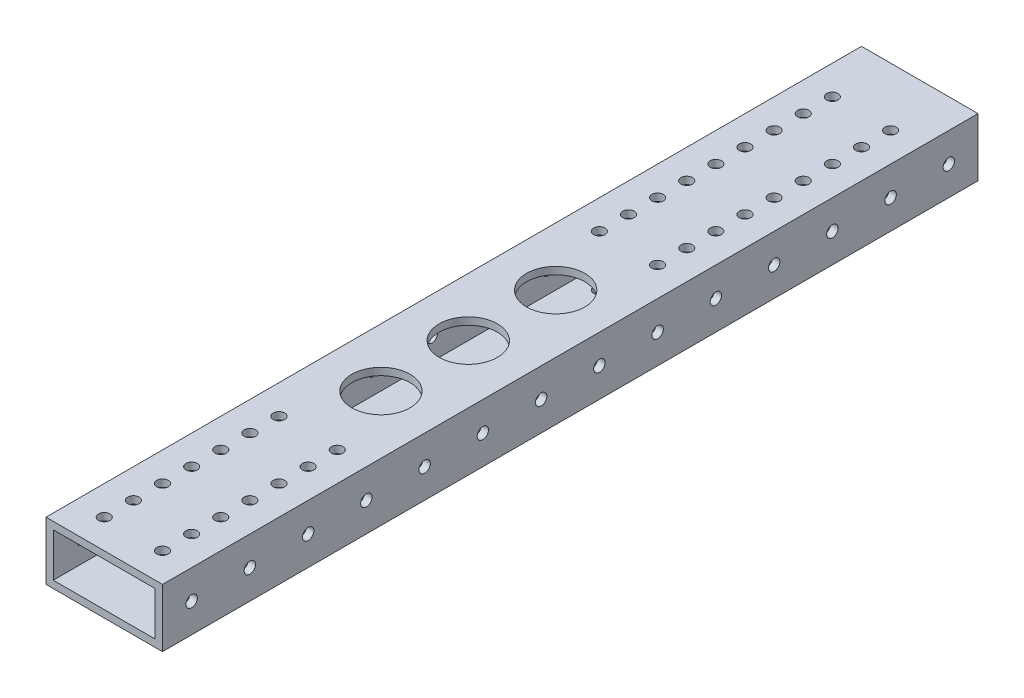
from build123d import *

# Parameters (mm, degrees)
SKETCH1_W           = 50.8
SKETCH1_H           = 25.4
SKETCH1_W_2         = 44.45
SKETCH1_H_2         = 19.05
BOSS_EXTRUDE1_DEPTH = 177.8
CUT_EXTRUDE1_REACH  = 27.4
SKETCH2_R           = 2.4892
SKETCH3_R           = 2.4892
CUT_EXTRUDE2_DEPTH  = 51.8
SKETCH4_R           = 2.4892
CUT_EXTRUDE3_DEPTH  = 26.4
SKETCH5_R           = 12.7
CUT_EXTRUDE4_DEPTH  = 26.4


with BuildPart() as part:
    # Sketch1 → Boss-Extrude1 (new body, symmetric)
    with BuildSketch(Plane.XY):
        Rectangle(SKETCH1_W, SKETCH1_H)
        Rectangle(SKETCH1_W_2, SKETCH1_H_2, mode=Mode.SUBTRACT)
    extrude(amount=BOSS_EXTRUDE1_DEPTH, both=True)

    # Sketch2 → Cut-Extrude1 (cut, up to next)
    with BuildSketch(Plane.XZ.offset(-12.7), mode=Mode.PRIVATE) as cut_extrude1_sk1:
        with Locations((-12.7, 165.1)):
            Circle(SKETCH2_R)
    cut_extrude1_tool1 = extrude(cut_extrude1_sk1.sketch, amount=CUT_EXTRUDE1_REACH, mode=Mode.PRIVATE) & part.part
    add(cut_extrude1_tool1.solids().sort_by_distance((-12.7, 12.7, 165.1))[0], mode=Mode.SUBTRACT)
    # Sketch2 → Cut-Extrude1 (cut, up to next)
    with BuildSketch(Plane.XZ.offset(-12.7), mode=Mode.PRIVATE) as cut_extrude1_sk2:
        with Locations((-12.7, 152.4)):
            Circle(SKETCH2_R)
    cut_extrude1_tool2 = extrude(cut_extrude1_sk2.sketch, amount=CUT_EXTRUDE1_REACH, mode=Mode.PRIVATE) & part.part
    add(cut_extrude1_tool2.solids().sort_by_distance((-12.7, 12.7, 152.4))[0], mode=Mode.SUBTRACT)
    # Sketch2 → Cut-Extrude1 (cut, up to next)
    with BuildSketch(Plane.XZ.offset(-12.7), mode=Mode.PRIVATE) as cut_extrude1_sk3:
        with Locations((-12.7, 139.7)):
            Circle(SKETCH2_R)
    cut_extrude1_tool3 = extrude(cut_extrude1_sk3.sketch, amount=CUT_EXTRUDE1_REACH, mode=Mode.PRIVATE) & part.part
    add(cut_extrude1_tool3.solids().sort_by_distance((-12.7, 12.7, 139.7))[0], mode=Mode.SUBTRACT)
    # Sketch2 → Cut-Extrude1 (cut, up to next)
    with BuildSketch(Plane.XZ.offset(-12.7), mode=Mode.PRIVATE) as cut_extrude1_sk4:
        with Locations((-12.7, 127)):
            Circle(SKETCH2_R)
    cut_extrude1_tool4 = extrude(cut_extrude1_sk4.sketch, amount=CUT_EXTRUDE1_REACH, mode=Mode.PRIVATE) & part.part
    add(cut_extrude1_tool4.solids().sort_by_distance((-12.7, 12.7, 127))[0], mode=Mode.SUBTRACT)
    # Sketch2 → Cut-Extrude1 (cut, up to next)
    with BuildSketch(Plane.XZ.offset(-12.7), mode=Mode.PRIVATE) as cut_extrude1_sk5:
        with Locations((-12.7, 114.3)):
            Circle(SKETCH2_R)
    cut_extrude1_tool5 = extrude(cut_extrude1_sk5.sketch, amount=CUT_EXTRUDE1_REACH, mode=Mode.PRIVATE) & part.part
    add(cut_extrude1_tool5.solids().sort_by_distance((-12.7, 12.7, 114.3))[0], mode=Mode.SUBTRACT)
    # Sketch2 → Cut-Extrude1 (cut, up to next)
    with BuildSketch(Plane.XZ.offset(-12.7), mode=Mode.PRIVATE) as cut_extrude1_sk6:
        with Locations((-12.7, 101.6)):
            Circle(SKETCH2_R)
    cut_extrude1_tool6 = extrude(cut_extrude1_sk6.sketch, amount=CUT_EXTRUDE1_REACH, mode=Mode.PRIVATE) & part.part
    add(cut_extrude1_tool6.solids().sort_by_distance((-12.7, 12.7, 101.6))[0], mode=Mode.SUBTRACT)
    # Sketch2 → Cut-Extrude1 (cut, up to next)
    with BuildSketch(Plane.XZ.offset(-12.7), mode=Mode.PRIVATE) as cut_extrude1_sk7:
        with Locations((-12.7, 88.9)):
            Circle(SKETCH2_R)
    cut_extrude1_tool7 = extrude(cut_extrude1_sk7.sketch, amount=CUT_EXTRUDE1_REACH, mode=Mode.PRIVATE) & part.part
    add(cut_extrude1_tool7.solids().sort_by_distance((-12.7, 12.7, 88.9))[0], mode=Mode.SUBTRACT)
    # Sketch2 → Cut-Extrude1 (cut, up to next)
    with BuildSketch(Plane.XZ.offset(-12.7), mode=Mode.PRIVATE) as cut_extrude1_sk8:
        with Locations((12.7, 165.1)):
            Circle(SKETCH2_R)
    cut_extrude1_tool8 = extrude(cut_extrude1_sk8.sketch, amount=CUT_EXTRUDE1_REACH, mode=Mode.PRIVATE) & part.part
    add(cut_extrude1_tool8.solids().sort_by_distance((12.7, 12.7, 165.1))[0], mode=Mode.SUBTRACT)
    # Sketch2 → Cut-Extrude1 (cut, up to next)
    with BuildSketch(Plane.XZ.offset(-12.7), mode=Mode.PRIVATE) as cut_extrude1_sk9:
        with Locations((12.7, 152.4)):
            Circle(SKETCH2_R)
    cut_extrude1_tool9 = extrude(cut_extrude1_sk9.sketch, amount=CUT_EXTRUDE1_REACH, mode=Mode.PRIVATE) & part.part
    add(cut_extrude1_tool9.solids().sort_by_distance((12.7, 12.7, 152.4))[0], mode=Mode.SUBTRACT)
    # Sketch2 → Cut-Extrude1 (cut, up to next)
    with BuildSketch(Plane.XZ.offset(-12.7), mode=Mode.PRIVATE) as cut_extrude1_sk10:
        with Locations((12.7, 139.7)):
            Circle(SKETCH2_R)
    cut_extrude1_tool10 = extrude(cut_extrude1_sk10.sketch, amount=CUT_EXTRUDE1_REACH, mode=Mode.PRIVATE) & part.part
    add(cut_extrude1_tool10.solids().sort_by_distance((12.7, 12.7, 139.7))[0], mode=Mode.SUBTRACT)
    # Sketch2 → Cut-Extrude1 (cut, up to next)
    with BuildSketch(Plane.XZ.offset(-12.7), mode=Mode.PRIVATE) as cut_extrude1_sk11:
        with Locations((12.7, 127)):
            Circle(SKETCH2_R)
    cut_extrude1_tool11 = extrude(cut_extrude1_sk11.sketch, amount=CUT_EXTRUDE1_REACH, mode=Mode.PRIVATE) & part.part
    add(cut_extrude1_tool11.solids().sort_by_distance((12.7, 12.7, 127))[0], mode=Mode.SUBTRACT)
    # Sketch2 → Cut-Extrude1 (cut, up to next)
    with BuildSketch(Plane.XZ.offset(-12.7), mode=Mode.PRIVATE) as cut_extrude1_sk12:
        with Locations((12.7, 114.3)):
            Circle(SKETCH2_R)
    cut_extrude1_tool12 = extrude(cut_extrude1_sk12.sketch, amount=CUT_EXTRUDE1_REACH, mode=Mode.PRIVATE) & part.part
    add(cut_extrude1_tool12.solids().sort_by_distance((12.7, 12.7, 114.3))[0], mode=Mode.SUBTRACT)
    # Sketch2 → Cut-Extrude1 (cut, up to next)
    with BuildSketch(Plane.XZ.offset(-12.7), mode=Mode.PRIVATE) as cut_extrude1_sk13:
        with Locations((12.7, 101.6)):
            Circle(SKETCH2_R)
    cut_extrude1_tool13 = extrude(cut_extrude1_sk13.sketch, amount=CUT_EXTRUDE1_REACH, mode=Mode.PRIVATE) & part.part
    add(cut_extrude1_tool13.solids().sort_by_distance((12.7, 12.7, 101.6))[0], mode=Mode.SUBTRACT)
    # Sketch2 → Cut-Extrude1 (cut, up to next)
    with BuildSketch(Plane.XZ.offset(-12.7), mode=Mode.PRIVATE) as cut_extrude1_sk14:
        with Locations((12.7, 88.9)):
            Circle(SKETCH2_R)
    cut_extrude1_tool14 = extrude(cut_extrude1_sk14.sketch, amount=CUT_EXTRUDE1_REACH, mode=Mode.PRIVATE) & part.part
    add(cut_extrude1_tool14.solids().sort_by_distance((12.7, 12.7, 88.9))[0], mode=Mode.SUBTRACT)

    # Sketch3 → Cut-Extrude2 (cut, through all)
    with BuildSketch(Plane(origin=(25.4, 0, 0), x_dir=(0, 0, -1), z_dir=(1, 0, 0))):
        with Locations((-165.1, 0)):
            Circle(SKETCH3_R)
        with Locations((-139.7, 0)):
            Circle(SKETCH3_R)
        with Locations((-114.3, 0)):
            Circle(SKETCH3_R)
        with Locations((-88.9, 0)):
            Circle(SKETCH3_R)
        with Locations((-63.5, 0)):
            Circle(SKETCH3_R)
        with Locations((-38.1, 0)):
            Circle(SKETCH3_R)
        with Locations((-12.7, 0)):
            Circle(SKETCH3_R)
        with Locations((12.7, 0)):
            Circle(SKETCH3_R)
        with Locations((38.1, 0)):
            Circle(SKETCH3_R)
        with Locations((63.5, 0)):
            Circle(SKETCH3_R)
        with Locations((88.9, 0)):
            Circle(SKETCH3_R)
        with Locations((114.3, 0)):
            Circle(SKETCH3_R)
        with Locations((139.7, 0)):
            Circle(SKETCH3_R)
        with Locations((165.1, 0)):
            Circle(SKETCH3_R)
    extrude(amount=-CUT_EXTRUDE2_DEPTH, mode=Mode.SUBTRACT)

    # Sketch4 → Cut-Extrude3 (cut, through all)
    with BuildSketch(Plane.XZ.offset(12.7)):
        with Locations((-12.7, -152.4)):
            Circle(SKETCH4_R)
        with Locations((-12.7, -139.7)):
            Circle(SKETCH4_R)
        with Locations((-12.7, -127)):
            Circle(SKETCH4_R)
        with Locations((-12.7, -114.3)):
            Circle(SKETCH4_R)
        with Locations((-12.7, -101.6)):
            Circle(SKETCH4_R)
        with Locations((-12.7, -88.9)):
            Circle(SKETCH4_R)
        with Locations((-12.7, -76.2)):
            Circle(SKETCH4_R)
        with Locations((-12.7, -63.5)):
            Circle(SKETCH4_R)
        with Locations((-12.7, -50.8)):
            Circle(SKETCH4_R)
        with Locations((12.7, -50.8)):
            Circle(SKETCH4_R)
        with Locations((12.7, -63.5)):
            Circle(SKETCH4_R)
        with Locations((12.7, -76.2)):
            Circle(SKETCH4_R)
        with Locations((12.7, -88.9)):
            Circle(SKETCH4_R)
        with Locations((12.7, -101.6)):
            Circle(SKETCH4_R)
        with Locations((12.7, -114.3)):
            Circle(SKETCH4_R)
        with Locations((12.7, -127)):
            Circle(SKETCH4_R)
        with Locations((12.7, -139.7)):
            Circle(SKETCH4_R)
        with Locations((12.7, -152.4)):
            Circle(SKETCH4_R)
    extrude(amount=-CUT_EXTRUDE3_DEPTH, mode=Mode.SUBTRACT)

    # Sketch5 → Cut-Extrude4 (cut, through all)
    with BuildSketch(Plane(origin=(0, 12.7, 0), x_dir=(1, 0, 0), z_dir=(0, 1, 0))):
        with Locations((0, -57.15)):
            Circle(SKETCH5_R)
        with Locations((0, -19.05)):
            Circle(SKETCH5_R)
        with Locations((0, 19.05)):
            Circle(SKETCH5_R)
    extrude(amount=-CUT_EXTRUDE4_DEPTH, mode=Mode.SUBTRACT)


solid = part.part
